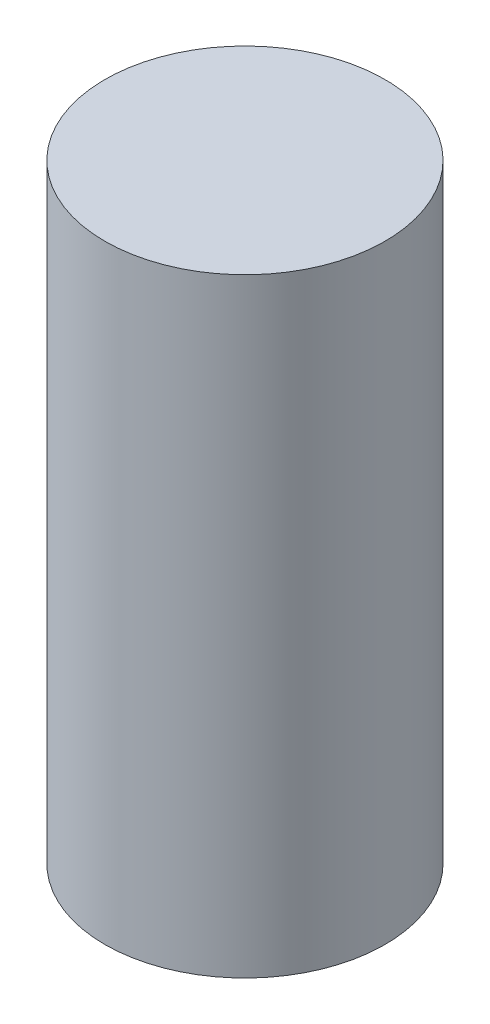
from build123d import *

# Parameters (mm, degrees)
ESBO_O1_R                = 8.05
RESSALTO_EXTRUS_O1_DEPTH = 35


with BuildPart() as part:
    # Esboço1 → Ressalto-extrusão1 (new body)
    with BuildSketch(Plane(origin=(0, 0, 0), x_dir=(1, 0, 0), z_dir=(0, 1, 0))):
        Circle(ESBO_O1_R)
    extrude(amount=RESSALTO_EXTRUS_O1_DEPTH)


solid = part.part
